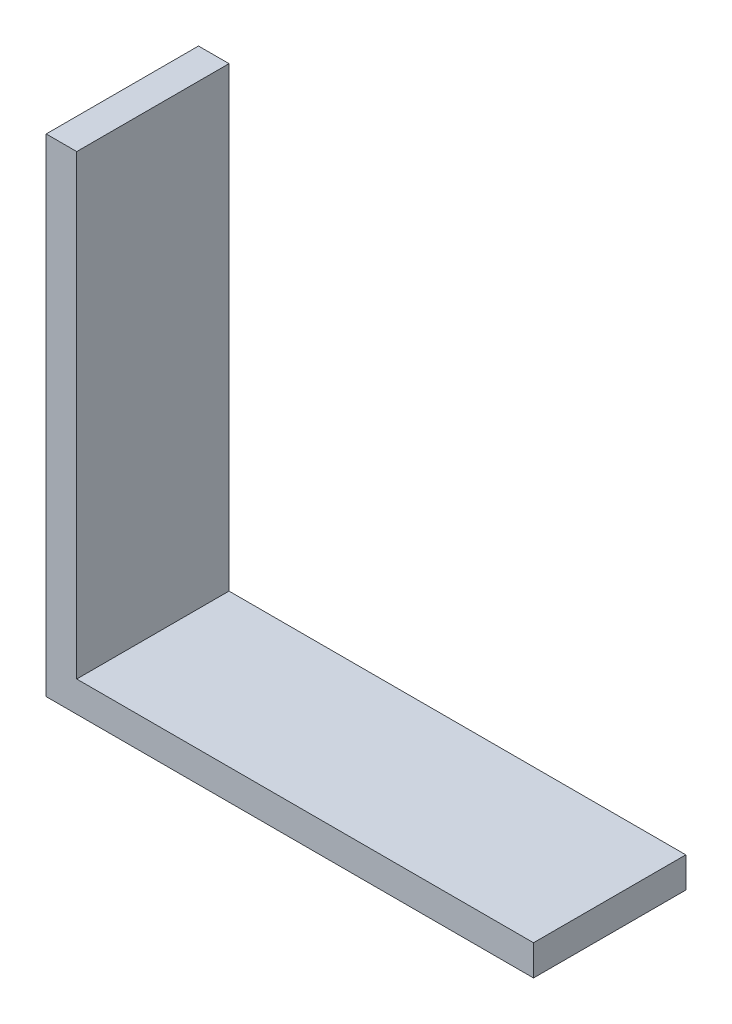
from build123d import *

# Parameters (mm, degrees)
BOSS_EXTRUDE1_DEPTH = 11.90625


with BuildPart() as part:
    # Sketch1 → Boss-Extrude1 (new body, symmetric)
    with BuildSketch(Plane.XY):
        Polygon((0, 0), (0, 76.2), (4.7752, 76.2), (4.7752, 4.7752), (76.2, 4.7752), (76.2, 0), align=None)
    extrude(amount=BOSS_EXTRUDE1_DEPTH, both=True)


solid = part.part
